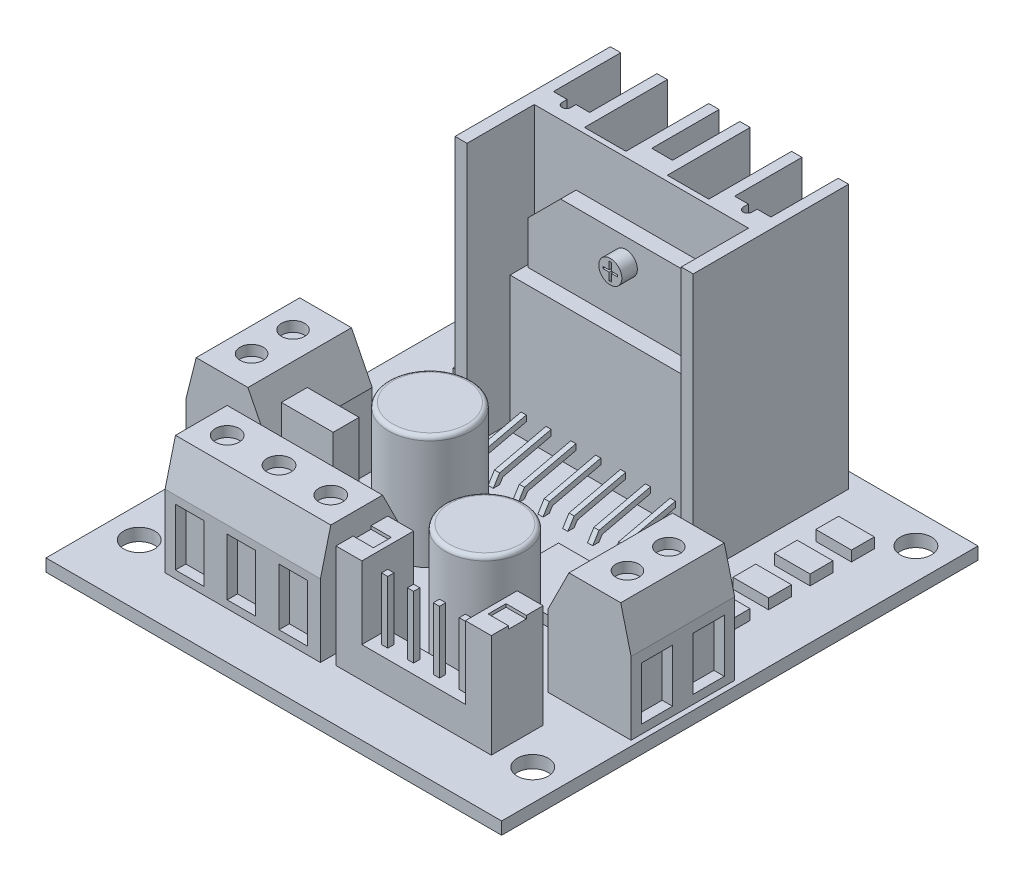
from build123d import *

# Parameters (mm, degrees)
CROQUIS1_W                    = 44
CROQUIS1_H                    = 46
CROQUIS1_R                    = 1.5
SALIENTE_EXTRUIR1_DEPTH       = 1.2
SALIENTE_EXTRUIR2_DEPTH       = 25.5
CROQUIS3_W                    = 19.365308418
CROQUIS3_H                    = 6.533489043
SALIENTE_EXTRUIR3_DEPTH       = 1.5
CROQUIS4_W                    = 19.365308418
CROQUIS4_H                    = 13.066978086
CROQUIS4_R                    = 1.114280983
SALIENTE_EXTRUIR4_DEPTH       = 1.5
SALIENTE_EXTRUIR5_DEPTH       = 0.25
MATRIZL1_COUNT                = 8
MATRIZL1_PITCH                = 2.4
CROQUIS7_W                    = 3.447043621
CROQUIS7_H                    = 2.206107918
CROQUIS7_W_2                  = 5.797195258
CROQUIS7_H_2                  = 6.532622161
SALIENTE_EXTRUIR6_DEPTH       = 1
CROQUIS8_W                    = 8
CROQUIS8_H                    = 10
SALIENTE_EXTRUIR7_DEPTH       = 11
CORTAR_EXTRUIR1_DEPTH         = 11
CROQUIS10_R                   = 1.111029377
CORTAR_EXTRUIR2_DEPTH         = 1
CROQUIS11_W                   = 3
CROQUIS11_H                   = 5.114159263
CORTAR_EXTRUIR3_DEPTH         = 1
CROQUIS12_W                   = 15
CROQUIS12_H                   = 8
SALIENTE_EXTRUIR8_DEPTH       = 11
CORTAR_EXTRUIR4_DEPTH         = 15
CROQUIS14_R                   = 1.153320406
CORTAR_EXTRUIR5_DEPTH         = 1
CROQUIS15_W                   = 2.751640039
CROQUIS15_H                   = 5.503280077
CORTAR_EXTRUIR6_DEPTH         = 1
CROQUIS16_W                   = 15
CROQUIS16_H                   = 2.5
SALIENTE_EXTRUIR9_DEPTH       = 3
CROQUIS17_W                   = 0.6
CROQUIS17_H                   = 0.6
SALIENTE_EXTRUIR10_DEPTH      = 6
CROQUIS18_W                   = 2.5
CROQUIS18_H                   = 5
SALIENTE_EXTRUIR11_DEPTH      = 7
SALIENTE_EXTRUIR11_DEPTH_BACK = 4.2
CROQUIS19_W                   = 1.961135145
CROQUIS19_H                   = 1.727519932
CORTAR_EXTRUIR7_DEPTH         = 0.3
CROQUIS20_R                   = 3.991253797
CROQUIS20_R_2                 = 3.810659562
CROQUIS20_W                   = 5
CROQUIS20_H                   = 2.5
SALIENTE_EXTRUIR12_DEPTH      = 11
REDONDEO1_R                   = 0.4


with BuildPart() as part:
    # Croquis1 → Saliente-Extruir1 (new body)
    with BuildSketch(Plane(origin=(0, 0, 0), x_dir=(1, 0, 0), z_dir=(0, 1, 0))):
        Rectangle(CROQUIS1_W, CROQUIS1_H)
        with Locations((-19, 20)):
            Circle(CROQUIS1_R, mode=Mode.SUBTRACT)
        with Locations((-19, -17)):
            Circle(CROQUIS1_R, mode=Mode.SUBTRACT)
        with Locations((19, -17)):
            Circle(CROQUIS1_R, mode=Mode.SUBTRACT)
        with Locations((19, 20)):
            Circle(CROQUIS1_R, mode=Mode.SUBTRACT)
    extrude(amount=SALIENTE_EXTRUIR1_DEPTH)

    # Croquis2 → Saliente-Extruir2 (add)
    with BuildSketch(Plane(origin=(0, 1.2, 0), x_dir=(1, 0, 0), z_dir=(0, 1, 0))):
        with BuildLine():
            Line((8.67693618, 15), (8.67693618, 14.506211674))
            ThreePointArc((8.67693618, 14.506211674), (8.25, 14.079275494), (7.82306382, 14.506211674))
            Line((7.82306382, 14.506211674), (7.82306382, 15))
            Line((7.82306382, 15), (6.5, 15))
            Line((6.5, 15), (6.5, 21.5))
            Line((6.5, 21.5), (5.5, 21.5))
            Line((5.5, 21.5), (5.5, 13.5))
            Line((5.5, 13.5), (1.5, 13.5))
            Line((1.5, 13.5), (1.5, 21.5))
            Line((1.5, 21.5), (0.5, 21.5))
            Line((0.5, 21.5), (0.5, 15))
            Line((0.5, 15), (-1.5, 15))
            Line((-1.5, 15), (-1.5, 21.5))
            Line((-1.5, 21.5), (-2.5, 21.5))
            Line((-2.5, 21.5), (-2.5, 13.5))
            Line((-2.5, 13.5), (-6.5, 13.5))
            Line((-6.5, 13.5), (-6.5, 21.5))
            Line((-6.5, 21.5), (-7.5, 21.5))
            Line((-7.5, 21.5), (-7.5, 15))
            Line((-7.5, 15), (-8.82306382, 15))
            Line((-8.82306382, 15), (-8.82306382, 14.506211674))
            ThreePointArc((-8.82306382, 14.506211674), (-9.25, 14.079275494), (-9.67693618, 14.506211674))
            Line((-9.67693618, 14.506211674), (-9.67693618, 15))
            Line((-9.67693618, 15), (-11, 15))
            Line((-11, 15), (-11, 21.5))
            Line((-11, 21.5), (-12, 21.5))
            Line((-12, 21.5), (-12, 6.5))
            Line((-12, 6.5), (-10.843156937, 6.5))
            Line((-10.843156937, 6.5), (-10.843156937, 7.006410896))
            Line((-10.843156937, 7.006410896), (-10.843156937, 12.993589104))
            Line((-10.843156937, 12.993589104), (9.843156937, 12.993589104))
            Line((9.843156937, 12.993589104), (9.843156937, 7.006410896))
            Line((9.843156937, 7.006410896), (9.843156937, 6.5))
            Line((9.843156937, 6.5), (11, 6.5))
            Line((11, 6.5), (11, 21.5))
            Line((11, 21.5), (10, 21.5))
            Line((10, 21.5), (10, 15))
            Line((10, 15), (8.67693618, 15))
        make_face()
    extrude(amount=SALIENTE_EXTRUIR2_DEPTH)

    # Croquis3 → Saliente-Extruir3 (add)
    with BuildSketch(Plane.XY.offset(-12.993589104)):
        Polygon((-9.937068109, 18.429294391), (-9.937068109, 14.266978086), (8.937068109, 14.266978086), (8.937068109, 18.429294391), (5.801399633, 21.564962866), (-6.801399633, 21.564962866), align=None)
        Polygon((-10.182654209, 14.266978086), (-10.182654209, 7.733489043), (9.182654209, 7.733489043), (9.182654209, 14.266978086), (8.937068109, 14.266978086), (-9.937068109, 14.266978086), align=None)
        with Locations((-0.5, 4.466744522)):
            Rectangle(CROQUIS3_W, CROQUIS3_H)
    extrude(amount=SALIENTE_EXTRUIR3_DEPTH)

    # Croquis4 → Saliente-Extruir4 (add)
    with BuildSketch(Plane.XY.offset(-11.493589104)):
        with Locations((-0.5, 7.733489043)):
            Rectangle(CROQUIS4_W, CROQUIS4_H)
        with Locations((-0.5, 19.387387499)):
            Circle(CROQUIS4_R)
        Polygon((-0.605818044, 19.476799013), (-0.605818044, 20.210681013), (-0.394181956, 20.210681013), (-0.394181956, 19.476799013), (0.195646193, 19.476799013), (0.195646193, 19.297975984), (-0.394181956, 19.297975984), (-0.394181956, 18.564093985), (-0.605818044, 18.564093985), (-0.605818044, 19.297975984), (-1.195646193, 19.297975984), (-1.195646193, 19.476799013), align=None, mode=Mode.SUBTRACT)
    extrude(amount=SALIENTE_EXTRUIR4_DEPTH)

    # Croquis6 → Saliente-Extruir5 (add, symmetric)
    with BuildSketch(Plane(origin=(7.932654209, 0, 0), x_dir=(0, 0, -1), z_dir=(1, 0, 0))):
        Polygon((9.993589104, 3.342388637), (5.02253535, 2.184888931), (4.409678304, 1.2), (5.02253535, 1.2), (5.328963873, 1.692444466), (9.993589104, 2.778592916), align=None)
    saliente_extruir5 = extrude(amount=SALIENTE_EXTRUIR5_DEPTH, both=True)

    # MatrizL1: Saliente-Extruir5 ×8
    with Locations(*[(-i * MATRIZL1_PITCH, 0, 0) for i in range(1, MATRIZL1_COUNT)]):
        add(saliente_extruir5)

    # Croquis7 → Saliente-Extruir6 (add)
    with BuildSketch(Plane(origin=(0, 1.2, 0), x_dir=(1, 0, 0), z_dir=(0, 1, 0))):
        with Locations((-15.511696297, 16.649220692)):
            Rectangle(CROQUIS7_W, CROQUIS7_H)
        with Locations((-15.511696297, 12.649220692)):
            Rectangle(CROQUIS7_W, CROQUIS7_H)
        with Locations((-15.511696297, 8.649220692)):
            Rectangle(CROQUIS7_W, CROQUIS7_H)
        with Locations((-15.511696297, 4.649220692)):
            Rectangle(CROQUIS7_W, CROQUIS7_H)
        with Locations((15.511696297, 4.649220692)):
            Rectangle(CROQUIS7_W, CROQUIS7_H)
        with Locations((15.511696297, 8.649220692)):
            Rectangle(CROQUIS7_W, CROQUIS7_H)
        with Locations((15.511696297, 12.649220692)):
            Rectangle(CROQUIS7_W, CROQUIS7_H)
        with Locations((15.511696297, 16.649220692)):
            Rectangle(CROQUIS7_W, CROQUIS7_H)
        with Locations((5.400924544, -1.273551097)):
            Rectangle(CROQUIS7_W_2, CROQUIS7_H_2)
    extrude(amount=SALIENTE_EXTRUIR6_DEPTH)

    # Croquis8 → Saliente-Extruir7 (add)
    with BuildSketch(Plane(origin=(0, 1.2, 0), x_dir=(1, 0, 0), z_dir=(0, 1, 0))):
        with Locations((-17.5, -5)):
            Rectangle(CROQUIS8_W, CROQUIS8_H)
    saliente_extruir7 = extrude(amount=SALIENTE_EXTRUIR7_DEPTH)

    # Croquis9 → Cortar-Extruir1 (cut)
    with BuildSketch(Plane.XY.offset(10)):
        Polygon((-21.5, 8.2), (-20.5, 12.2), (-21.5, 12.2), align=None)
        Polygon((-15.5, 12.2), (-13.5, 8.2), (-13.5, 12.2), align=None)
    cortar_extruir1 = extrude(amount=-CORTAR_EXTRUIR1_DEPTH, mode=Mode.SUBTRACT)

    # Croquis10 → Cortar-Extruir2 (cut)
    with BuildSketch(Plane(origin=(0, 12.2, 0), x_dir=(1, 0, 0), z_dir=(0, 1, 0))):
        with Locations((-18.14474212, -3)):
            Circle(CROQUIS10_R)
        with Locations((-18.14474212, -7)):
            Circle(CROQUIS10_R)
    cortar_extruir2 = extrude(amount=-CORTAR_EXTRUIR2_DEPTH, mode=Mode.SUBTRACT)

    # Croquis11 → Cortar-Extruir3 (cut)
    with BuildSketch(Plane.ZY.offset(21.5)):
        with Locations((2.5, 4.599585644)):
            Rectangle(CROQUIS11_W, CROQUIS11_H)
        with Locations((7.5, 4.599585644)):
            Rectangle(CROQUIS11_W, CROQUIS11_H)
    cortar_extruir3 = extrude(amount=-CORTAR_EXTRUIR3_DEPTH, mode=Mode.SUBTRACT)

    # Simetría1: Saliente-Extruir7, Cortar-Extruir1, Cortar-Extruir2, Cortar-Extruir3 across plane
    add(saliente_extruir7.mirror(Plane(origin=(0, 0, 0), x_dir=(0, 0, 1), z_dir=(1, 0, 0))))
    add(cortar_extruir1.mirror(Plane(origin=(0, 0, 0), x_dir=(0, 0, 1), z_dir=(1, 0, 0))), mode=Mode.SUBTRACT)
    add(cortar_extruir2.mirror(Plane(origin=(0, 0, 0), x_dir=(0, 0, 1), z_dir=(1, 0, 0))), mode=Mode.SUBTRACT)
    add(cortar_extruir3.mirror(Plane(origin=(0, 0, 0), x_dir=(0, 0, 1), z_dir=(1, 0, 0))), mode=Mode.SUBTRACT)

    # Croquis12 → Saliente-Extruir8 (add)
    with BuildSketch(Plane(origin=(0, 1.2, 0), x_dir=(1, 0, 0), z_dir=(0, 1, 0))):
        with Locations((-7.5, -14.5)):
            Rectangle(CROQUIS12_W, CROQUIS12_H)
    extrude(amount=SALIENTE_EXTRUIR8_DEPTH)

    # Croquis13 → Cortar-Extruir4 (cut)
    with BuildSketch(Plane(origin=(0, 0, 0), x_dir=(0, 0, -1), z_dir=(1, 0, 0))):
        Polygon((-18.5, 8.2), (-17.5, 12.2), (-18.5, 12.2), align=None)
        Polygon((-12.5, 12.2), (-10.5, 8.2), (-10.5, 12.2), align=None)
    extrude(amount=-CORTAR_EXTRUIR4_DEPTH, mode=Mode.SUBTRACT)

    # Croquis14 → Cortar-Extruir5 (cut)
    with BuildSketch(Plane(origin=(0, 12.2, 0), x_dir=(1, 0, 0), z_dir=(0, 1, 0))):
        with Locations((-12.5, -15)):
            Circle(CROQUIS14_R)
        with Locations((-7.5, -15)):
            Circle(CROQUIS14_R)
        with Locations((-2.5, -15)):
            Circle(CROQUIS14_R)
    extrude(amount=-CORTAR_EXTRUIR5_DEPTH, mode=Mode.SUBTRACT)

    # Croquis15 → Cortar-Extruir6 (cut)
    with BuildSketch(Plane.XY.offset(18.5)):
        with Locations((-12.62417998, 4.690290979)):
            Rectangle(CROQUIS15_W, CROQUIS15_H)
        with Locations((-7.624179981, 4.690290979)):
            Rectangle(CROQUIS15_W, CROQUIS15_H)
        with Locations((-2.624179981, 4.690290979)):
            Rectangle(CROQUIS15_W, CROQUIS15_H)
    extrude(amount=-CORTAR_EXTRUIR6_DEPTH, mode=Mode.SUBTRACT)

    # Croquis16 → Saliente-Extruir9 (add)
    with BuildSketch(Plane(origin=(0, 1.2, 0), x_dir=(1, 0, 0), z_dir=(0, 1, 0))):
        with Locations((8.5, -16.75)):
            Rectangle(CROQUIS16_W, CROQUIS16_H)
    extrude(amount=SALIENTE_EXTRUIR9_DEPTH)

    # Croquis17 → Saliente-Extruir10 (add)
    with BuildSketch(Plane(origin=(0, 4.2, 0), x_dir=(1, 0, 0), z_dir=(0, 1, 0))):
        with Locations((2.25, -16.75)):
            Rectangle(CROQUIS17_W, CROQUIS17_H)
        with Locations((4.75, -16.75)):
            Rectangle(CROQUIS17_W, CROQUIS17_H)
        with Locations((7.25, -16.75)):
            Rectangle(CROQUIS17_W, CROQUIS17_H)
        with Locations((9.75, -16.75)):
            Rectangle(CROQUIS17_W, CROQUIS17_H)
        with Locations((12.25, -16.75)):
            Rectangle(CROQUIS17_W, CROQUIS17_H)
        with Locations((14.75, -16.75)):
            Rectangle(CROQUIS17_W, CROQUIS17_H)
    extrude(amount=SALIENTE_EXTRUIR10_DEPTH)

    # Croquis18 → Saliente-Extruir11 (add, two sides)
    with BuildSketch(Plane(origin=(0, 4.2, 0), x_dir=(1, 0, 0), z_dir=(0, 1, 0))) as saliente_extruir11_sk:
        with Locations((2.25, -15.5)):
            Rectangle(CROQUIS18_W, CROQUIS18_H)
        with Locations((14.75, -15.5)):
            Rectangle(CROQUIS18_W, CROQUIS18_H)
    extrude(amount=SALIENTE_EXTRUIR11_DEPTH)
    extrude(saliente_extruir11_sk.sketch, amount=-SALIENTE_EXTRUIR11_DEPTH_BACK)

    # Croquis19 → Cortar-Extruir7 (cut)
    with BuildSketch(Plane(origin=(0, 11.2, 0), x_dir=(1, 0, 0), z_dir=(0, 1, 0))):
        with Locations((1.980567573, -15.479633985)):
            Rectangle(CROQUIS19_W, CROQUIS19_H)
        with Locations((15.019432427, -15.479633985)):
            Rectangle(CROQUIS19_W, CROQUIS19_H)
    extrude(amount=-CORTAR_EXTRUIR7_DEPTH, mode=Mode.SUBTRACT)

    # Croquis20 → Saliente-Extruir12 (add)
    with BuildSketch(Plane(origin=(0, 1.2, 0), x_dir=(1, 0, 0), z_dir=(0, 1, 0))):
        with Locations((-5.460117096, -2.464636189)):
            Circle(CROQUIS20_R)
        with Locations((7.355991088, -9.972297197)):
            Circle(CROQUIS20_R_2)
        with Locations((-10.13817835, -8.382004926)):
            Rectangle(CROQUIS20_W, CROQUIS20_H)
    extrude(amount=SALIENTE_EXTRUIR12_DEPTH)

    # Redondeo1
    redondeo1_edges = [part.edges().sort_by_distance(p)[0] for p in [
        (-9.451370893, 12.2, 2.464636189),
        (3.545331526, 12.2, 9.972297197),
    ]]
    fillet(redondeo1_edges, radius=REDONDEO1_R)


solid = part.part
